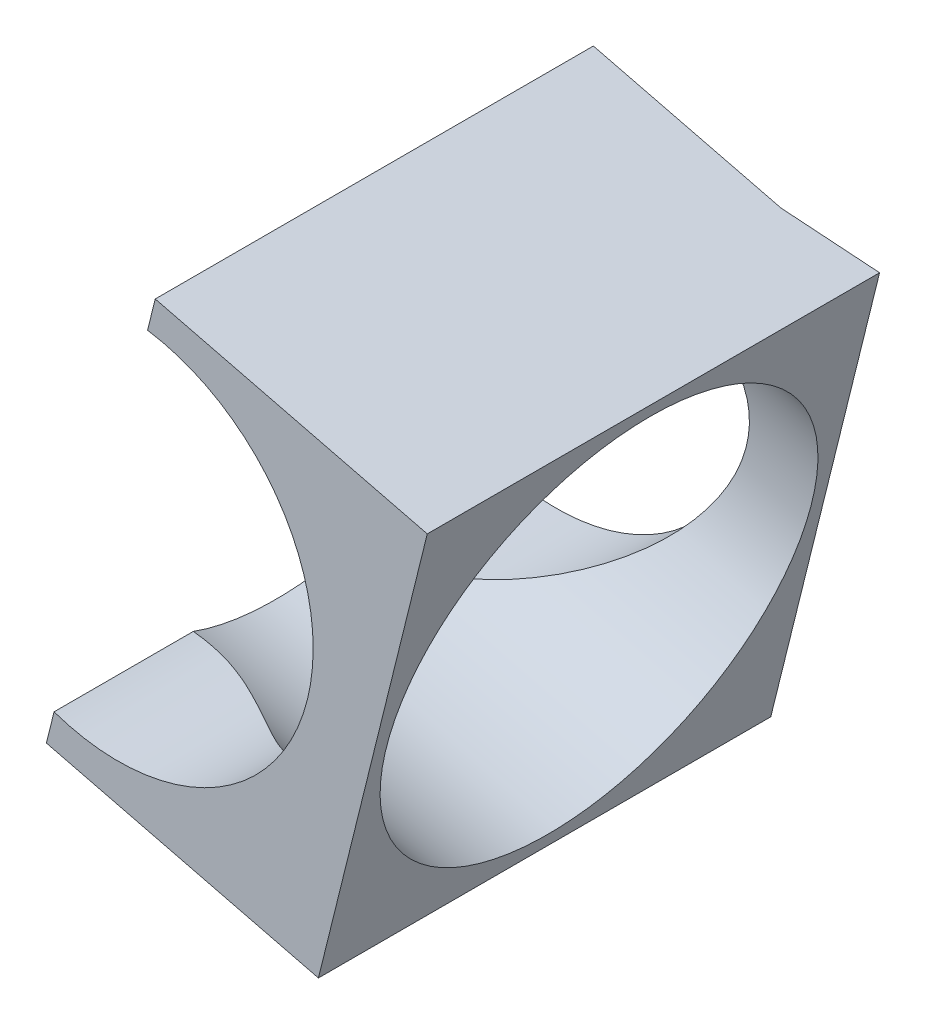
from build123d import *

# Parameters (mm, degrees)
RESSALTO_EXTRUS_O1_DEPTH = 25.5
CORTE_EXTRUS_O1_DEPTH    = 30.19013409
ESBO_O3_R                = 12
CORTE_EXTRUS_O2_DEPTH    = 22.755596158


with BuildPart() as part:
    # Esboço1 → Ressalto-extrusão1 (new body)
    with BuildSketch(Plane.XY):
        with BuildLine():
            Line((17.433095525, 13.814174971), (2.097319146, 17.616011747))
            Line((2.097319146, 17.616011747), (1.665269548, 15.873218352))
            ThreePointArc((1.665269548, 15.873218352), (10.676806339, 2.353151612), (-3.606507064, -5.391973191))
            Line((-3.606507064, -5.391973191), (-4.038556662, -7.134766585))
            Line((-4.038556662, -7.134766585), (11.297219716, -10.936603361))
            Line((11.297219716, -10.936603361), (17.433095525, 13.814174971))
        make_face()
    extrude(amount=-RESSALTO_EXTRUS_O1_DEPTH)

    # Esboço2 → Corte-extrusão1 (cut, through all)
    with BuildSketch(Plane(origin=(4.235701857, 17.085893034, 0), x_dir=(0, 0, 1), z_dir=(0.240622581, 0.970618758, 0))):
        Polygon((-24.7, -2.203112904), (-24.7, 8.696887096), (-25.5, 13.596887096), (-25.5, -2.203112904), align=None)
    extrude(amount=-CORTE_EXTRUS_O1_DEPTH, mode=Mode.SUBTRACT)

    # Esboço3 → Corte-extrusão2 (cut, through all)
    with BuildSketch(Plane(origin=(13.197393668, -3.271718063, 0), x_dir=(-0.240622581, -0.970618758, 0), z_dir=(0.970618758, -0.240622581, 0))):
        with Locations((-4.853093791, 12.75)):
            Circle(ESBO_O3_R)
    extrude(amount=-CORTE_EXTRUS_O2_DEPTH, mode=Mode.SUBTRACT)


solid = part.part
